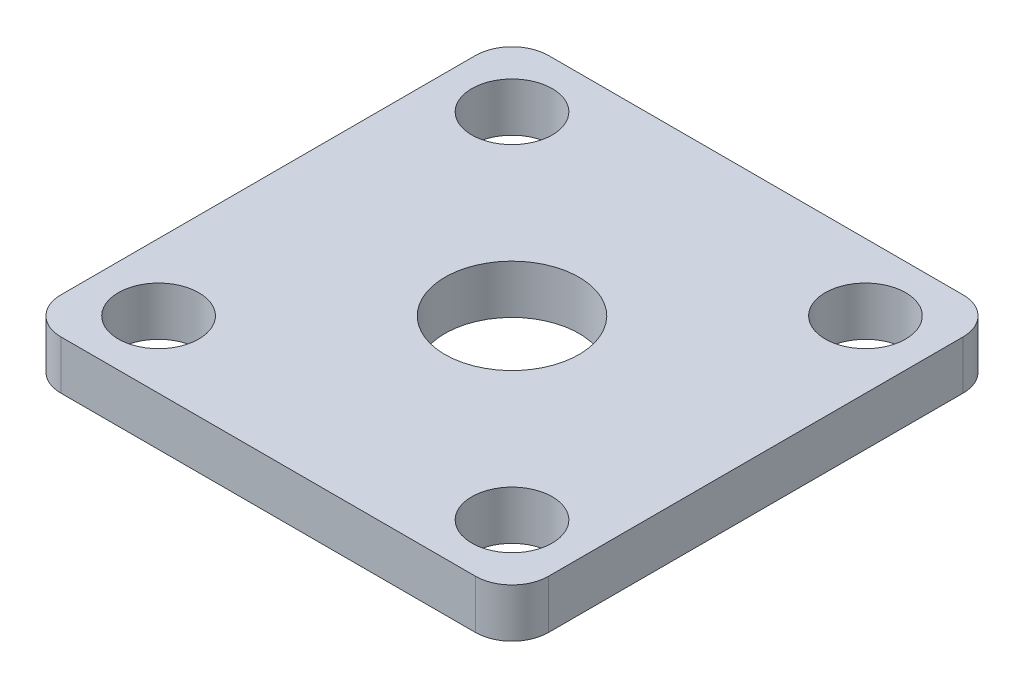
from build123d import *

# Parameters (mm, degrees)
SKETCH_1_W         = 40
SKETCH_1_H         = 40
EXTRUDE_1_DEPTH    = 4
HOLE_WIZARD_M101_D = 11
FILLET_1_R         = 3
HOLE_WIZARD_M61_D  = 6.6


with BuildPart() as part:
    # Эскиз1 → Бобышка-Вытянуть1 (new body)
    with BuildSketch(Plane(origin=(0, 0, 0), x_dir=(1, 0, 0), z_dir=(0, 1, 0))):
        Rectangle(SKETCH_1_W, SKETCH_1_H)
    extrude(amount=EXTRUDE_1_DEPTH)

    # Отверстие с зазором M101 (through all)
    with Locations(Plane(origin=(0, 4, 0), x_dir=(1, 0, 0), z_dir=(0, 1, 0))):
        with Locations((0, 0)):
            Hole(HOLE_WIZARD_M101_D / 2)

    # Скругление1
    fillet_1_edges = [part.edges().sort_by_distance(p)[0] for p in [
        (20, 2, 20),
        (-20, 2, 20),
        (-20, 2, -20),
        (20, 2, -20),
    ]]
    fillet(fillet_1_edges, radius=FILLET_1_R)

    # Отверстие с зазором M61 (through all)
    with Locations(Plane(origin=(0, 0, 0), x_dir=(-1, 0, 0), z_dir=(0, -1, 0))):
        with Locations((-14.5, 14.5), (0, 0), (14.5, 14.5), (-14.5, -14.5), (14.5, -14.5)):
            Hole(HOLE_WIZARD_M61_D / 2)


solid = part.part
